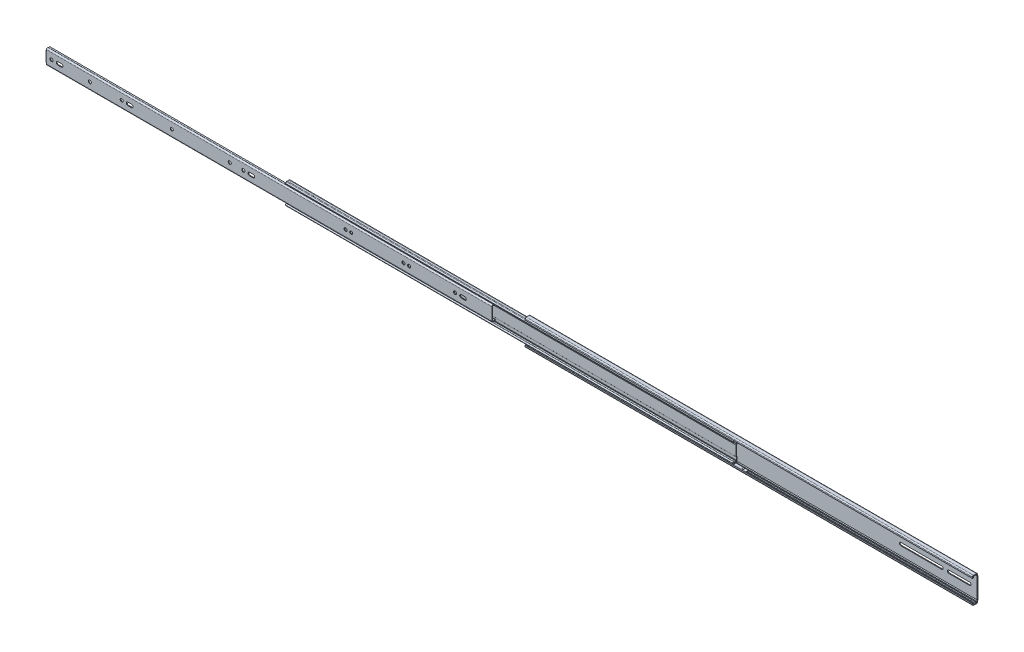
from build123d import *

# Parameters (mm, degrees)
EXTRUDE1_DEPTH      = 711.2
EXTRUDE_THIN3_DEPTH = 711.2
EXTRUDE_THIN4_DEPTH = 709.93
SKETCH4_W           = 1.7018
SKETCH4_H           = 3.807139541
CUT_EXTRUDE1_DEPTH  = 10.525
SKETCH5_W           = 1.1938
SKETCH5_H           = 8.001
EXTRUDE2_DEPTH      = 6.9088
FILLET1_R           = 0.508
FILLET2_R           = 1.7018
SKETCH6_R           = 2.4384
CUT_EXTRUDE2_DEPTH  = 1.1938
SKETCH7_R           = 2.4384
CUT_A_DEPTH         = 1.1938
SKETCH8_R           = 2.4384
CUT_B_DEPTH         = 1.1938
SKETCH9_R           = 2.4384
CUT_C_DEPTH         = 1.1938
SKETCH10_R          = 2.4384
CUT_D_DEPTH         = 1.1938
SKETCH11_R          = 2.4384
CUT_E_DEPTH         = 1.1938
SKETCH12_R          = 2.4384
CUT_F_DEPTH         = 1.1938
SKETCH13_R          = 2.286
CUT_EXTRUDE9_DEPTH  = 1.1938
LPATTERN1_COUNT     = 14
LPATTERN1_PITCH     = 25.4
SKETCH15_W          = 4.064
SKETCH15_H          = 0.762
EXTRUDE3_DEPTH      = 336.55
EXTRUDE3_DEPTH_BACK = 6.35
LPATTERN2_COUNT     = 12
LPATTERN2_PITCH     = 25.4
SKETCH17_W          = 3.81
SKETCH17_H          = 0.762
EXTRUDE4_DEPTH      = 285.75
EXTRUDE4_DEPTH_BACK = 6.35


with BuildPart() as part:
    # Sketch1 → Extrude1 (new body)
    with BuildSketch(Plane(origin=(0, 0, 0), x_dir=(0, 0, -1), z_dir=(1, 0, 0))):
        with BuildLine():
            Line((4.7498, 0), (3.556, 0))
            Line((3.556, 0), (3.556, 16.3322))
            Line((3.556, 16.3322), (2.794, 17.7546))
            Line((2.794, 17.7546), (2.794, 19.1897))
            ThreePointArc((2.794, 19.1897), (2.719605122, 19.369305122), (2.54, 19.4437))
            Line((2.54, 19.4437), (0.704935806, 19.4437))
            ThreePointArc((0.704935806, 19.4437), (0, 19.6088), (-0.704935806, 19.4437))
            Line((-0.704935806, 19.4437), (-2.286, 19.4437))
            ThreePointArc((-2.286, 19.4437), (-2.645210245, 19.294910245), (-2.794, 18.9357))
            Line((-2.794, 18.9357), (-2.794, 17.0942))
            Line((-2.794, 17.0942), (-3.9878, 17.0942))
            Line((-3.9878, 17.0942), (-3.9878, 18.9357))
            ThreePointArc((-3.9878, 18.9357), (-3.48935432, 20.13905432), (-2.286, 20.6375))
            Line((-2.286, 20.6375), (2.54, 20.6375))
            ThreePointArc((2.54, 20.6375), (3.563749198, 20.213449198), (3.9878, 19.1897))
            Line((3.9878, 19.1897), (3.9878, 17.7546))
            Line((3.9878, 17.7546), (4.7498, 16.3322))
            Line((4.7498, 16.3322), (4.7498, 0))
        make_face()
    extrude(amount=EXTRUDE1_DEPTH)

    # Sketch13 → Cut-Extrude9 (cut)
    with BuildSketch(Plane.XY.offset(-3.556)):
        with Locations((12.7, 0)):
            Circle(SKETCH13_R)
        with Locations((25.4, 0)):
            Circle(SKETCH13_R)
        with BuildLine():
            Line((43.942, 2.286), (57.658, 2.286))
            ThreePointArc((57.658, 2.286), (59.944, 0), (57.658, -2.286))
            Line((57.658, -2.286), (43.942, -2.286))
            ThreePointArc((43.942, -2.286), (41.656, 0), (43.942, 2.286))
        make_face()
        with BuildLine():
            Line((665.988, 2.286), (699.262, 2.286))
            ThreePointArc((699.262, 2.286), (701.548, 0), (699.262, -2.286))
            Line((699.262, -2.286), (665.988, -2.286))
            ThreePointArc((665.988, -2.286), (663.702, 0), (665.988, 2.286))
        make_face()
        with BuildLine():
            Line((589.788, 2.286), (654.812, 2.286))
            ThreePointArc((654.812, 2.286), (657.098, 0), (654.812, -2.286))
            Line((654.812, -2.286), (589.788, -2.286))
            ThreePointArc((589.788, -2.286), (587.502, 0), (589.788, 2.286))
        make_face()
    extrude(amount=-CUT_EXTRUDE9_DEPTH, mode=Mode.SUBTRACT)

    # Mirror1 3: part across plane


with BuildPart() as body_2:
    # Sketch2 → Extrude-Thin3 (new body)
    with BuildSketch(Plane(origin=(-381, 0, 0), x_dir=(0, 0, -1), z_dir=(1, 0, 0))):
        with BuildLine():
            Line((1.678205122, 13.56611667), (0.330795167, 13.56611667))
            ThreePointArc((0.330795167, 13.56611667), (-0.907153989, 14.137512866), (-2.131711722, 13.537954626))
            ThreePointArc((-2.131711722, 13.537954626), (-3.588398833, 13.622175049), (-4.000459023, 15.021902459))
            Line((-4.000459023, 15.021902459), (-2.6823632, 16.683501723))
            ThreePointArc((-2.6823632, 16.683501723), (-2.059327749, 17.098889851), (-1.31100655, 17.071763198))
            ThreePointArc((-1.31100655, 17.071763198), (0, 16.841067769), (1.31100655, 17.071763198))
            ThreePointArc((1.31100655, 17.071763198), (2.426851908, 16.924266748), (2.9464, 15.9258))
            Line((2.9464, 15.9258), (2.9464, 9.08690864))
            ThreePointArc((2.9464, 9.08690864), (2.836192787, 8.532859567), (2.522349198, 8.063159443))
            Line((2.522349198, 8.063159443), (2.062278771, 7.603089016))
            Line((2.062278771, 7.603089016), (2.062278771, 0))
            Line((2.062278771, 0), (0.868478771, 0))
            Line((0.868478771, 0), (0.868478771, 8.097577167))
            Line((0.868478771, 8.097577167), (1.678205122, 8.907303518))
            ThreePointArc((1.678205122, 8.907303518), (1.733265401, 8.989707049), (1.7526, 9.08690864))
            Line((1.7526, 9.08690864), (1.7526, 15.9258))
            ThreePointArc((1.7526, 15.9258), (1.741776081, 15.946601391), (1.718529303, 15.949674233))
            ThreePointArc((1.718529303, 15.949674233), (0, 15.647267769), (-1.718529303, 15.949674233))
            ThreePointArc((-1.718529303, 15.949674233), (-1.734119328, 15.950239372), (-1.747099233, 15.941585453))
            Line((-1.747099233, 15.941585453), (-2.845633379, 14.556766916))
            ThreePointArc((-2.845633379, 14.556766916), (-2.836333429, 14.550559856), (-2.826200697, 14.54583287))
            ThreePointArc((-2.826200697, 14.54583287), (-1.052921196, 15.326581965), (0.799909012, 14.75991667))
            Line((0.799909012, 14.75991667), (1.678205122, 14.75991667))
            Line((1.678205122, 14.75991667), (1.678205122, 13.56611667))
        make_face()
    extrude(amount=EXTRUDE_THIN3_DEPTH)

    # Mirror1: body 2 across plane


with BuildPart() as body_3:
    # Sketch3 → Extrude-Thin4 (new body)
    with BuildSketch(Plane(origin=(-762, 0, 0), x_dir=(0, 0, -1), z_dir=(1, 0, 0))):
        with BuildLine():
            Line((-4.7752, 0), (-4.7752, 9.979339541))
            ThreePointArc((-4.7752, 9.979339541), (-3.801640272, 11.595839932), (-1.917508053, 11.491255808))
            ThreePointArc((-1.917508053, 11.491255808), (-0.787981781, 11.177143004), (0.300186701, 11.613475229))
            Line((0.300186701, 11.613475229), (1.076210755, 10.706312009))
            ThreePointArc((1.076210755, 10.706312009), (-0.722289929, 9.985151804), (-2.589145852, 10.504310467))
            ThreePointArc((-2.589145852, 10.504310467), (-3.243358428, 10.540624399), (-3.5814, 9.979339541))
            Line((-3.5814, 9.979339541), (-3.5814, 0))
            Line((-3.5814, 0), (-4.7752, 0))
        make_face()
    extrude(amount=EXTRUDE_THIN4_DEPTH)

    # Sketch4 → Cut-Extrude1 (cut, through all)
    with BuildSketch(Plane.XY.offset(4.7752)):
        with Locations((-761.1491, 9.904569771)):
            Rectangle(SKETCH4_W, SKETCH4_H)
    extrude(amount=-CUT_EXTRUDE1_DEPTH, mode=Mode.SUBTRACT)

    # Sketch5 → Extrude2 (add)
    with BuildSketch(Plane.XY.offset(4.7752)):
        with Locations((-761.4031, 4.0005)):
            Rectangle(SKETCH5_W, SKETCH5_H)
    extrude(amount=-EXTRUDE2_DEPTH)

    # Fillet1
    fillet1_edges = [body_3.edges().sort_by_distance(p)[0] for p in [
        (-760.8062, 4.0005, 3.5814),
    ]]
    fillet(fillet1_edges, radius=FILLET1_R)

    # Fillet2
    fillet2_edges = [body_3.edges().sort_by_distance(p)[0] for p in [
        (-762, 4.0005, 4.7752),
    ]]
    fillet(fillet2_edges, radius=FILLET2_R)

    # Sketch6 → Cut-Extrude2 (cut)
    with BuildSketch(Plane.XY.offset(4.7752)):
        with Locations((-752.094, 0)):
            Circle(SKETCH6_R)
        with Locations((-691.388, 0)):
            Circle(SKETCH6_R)
        with Locations((-640.588, 0)):
            Circle(SKETCH6_R)
        with BuildLine():
            Line((-736.5873, -2.4384), (-742.2007, -2.4384))
            ThreePointArc((-742.2007, -2.4384), (-744.6391, 0), (-742.2007, 2.4384))
            Line((-742.2007, 2.4384), (-736.5873, 2.4384))
            ThreePointArc((-736.5873, 2.4384), (-734.1489, 0), (-736.5873, -2.4384))
        make_face()
        with BuildLine():
            Line((-625.0813, -2.4384), (-630.6947, -2.4384))
            ThreePointArc((-630.6947, -2.4384), (-633.1331, 0), (-630.6947, 2.4384))
            Line((-630.6947, 2.4384), (-625.0813, 2.4384))
            ThreePointArc((-625.0813, 2.4384), (-622.6429, 0), (-625.0813, -2.4384))
        make_face()
    extrude(amount=-CUT_EXTRUDE2_DEPTH, mode=Mode.SUBTRACT)

    # Sketch7 → Cut A (cut)
    with BuildSketch(Plane.XY.offset(4.7752)):
        with Locations((-560.959, 0)):
            Circle(SKETCH7_R)
    extrude(amount=-CUT_A_DEPTH, mode=Mode.SUBTRACT)

    # Sketch8 → Cut B (cut)
    with BuildSketch(Plane(origin=(33.28572008, 2.833820848, 4.7752), x_dir=(1, 0, 0), z_dir=(0, 0, 1))):
        with Locations((-502.16972008, -2.833820848)):
            Circle(SKETCH8_R)
    extrude(amount=-CUT_B_DEPTH, mode=Mode.SUBTRACT)

    # Sketch9 → Cut C (cut)
    with BuildSketch(Plane.XY.offset(4.7752)):
        with Locations((-447.294, 0)):
            Circle(SKETCH9_R)
        with BuildLine():
            Line((-431.7873, -2.4384), (-437.4007, -2.4384))
            ThreePointArc((-437.4007, -2.4384), (-439.8391, 0), (-437.4007, 2.4384))
            Line((-437.4007, 2.4384), (-431.7873, 2.4384))
            ThreePointArc((-431.7873, 2.4384), (-429.3489, 0), (-431.7873, -2.4384))
        make_face()
    extrude(amount=-CUT_C_DEPTH, mode=Mode.SUBTRACT)

    # Sketch10 → Cut D (cut)
    with BuildSketch(Plane.XY.offset(4.7752)):
        with Locations((-284.734, 0)):
            Circle(SKETCH10_R)
        with Locations((-275.844, 0)):
            Circle(SKETCH10_R)
    extrude(amount=-CUT_D_DEPTH, mode=Mode.SUBTRACT)

    # Sketch11 → Cut E (cut)
    with BuildSketch(Plane(origin=(55.847663356, 2.141084094, 4.7752), x_dir=(1, 0, 0), z_dir=(0, 0, 1))):
        with Locations((-248.506663356, -2.141084094)):
            Circle(SKETCH11_R)
        with Locations((-239.616663356, -2.141084094)):
            Circle(SKETCH11_R)
    extrude(amount=-CUT_E_DEPTH, mode=Mode.SUBTRACT)

    # Sketch12 → Cut F (cut)
    with BuildSketch(Plane(origin=(338.891405188, 2.462451908, 4.7752), x_dir=(1, 0, 0), z_dir=(0, 0, 1))):
        with Locations((-449.635405188, -2.462451908)):
            Circle(SKETCH12_R)
        with BuildLine():
            Line((-439.742105188, -4.900851908), (-434.128705188, -4.900851908))
            ThreePointArc((-434.128705188, -4.900851908), (-431.690305188, -2.462451908), (-434.128705188, -0.024051908))
            Line((-434.128705188, -0.024051908), (-439.742105188, -0.024051908))
            ThreePointArc((-439.742105188, -0.024051908), (-442.180505188, -2.462451908), (-439.742105188, -4.900851908))
        make_face()
    extrude(amount=-CUT_F_DEPTH, mode=Mode.SUBTRACT)

    # Mirror1 2: body 3 across plane


with BuildPart() as body_2_1:
    add(body_2.part)
    add(body_2.part.mirror(Plane.ZX))


with BuildPart() as body_3_1:
    add(body_3.part)
    add(body_3.part.mirror(Plane.ZX))


with BuildPart() as part_1:
    add(part.part)
    add(part.part.mirror(Plane.ZX))


with BuildPart() as body_4:
    # Sketch14 → Revolve1 (revolve)
    with BuildSketch(Plane(origin=(12.7, 0, 0), x_dir=(0, 0, -1), z_dir=(1, 0, 0))):
        with BuildLine():
            Line((0, 19.6088), (0, 16.841067769))
            ThreePointArc((0, 16.841067769), (1.383866115, 18.224933885), (0, 19.6088))
        make_face()
    revolve(axis=Axis((12.7, 20.062006868, 0), (0, -1, 0)))


with BuildPart() as lpattern1_1:
    # LPattern1: pattern copy
    add(body_4.part.moved(Location(Vector(1, 0, 0) * (1 * LPATTERN1_PITCH))))


with BuildPart() as lpattern1_2:
    # LPattern1: pattern copy
    add(body_4.part.moved(Location(Vector(1, 0, 0) * (2 * LPATTERN1_PITCH))))


with BuildPart() as lpattern1_3:
    # LPattern1: pattern copy
    add(body_4.part.moved(Location(Vector(1, 0, 0) * (3 * LPATTERN1_PITCH))))


with BuildPart() as lpattern1_4:
    # LPattern1: pattern copy
    add(body_4.part.moved(Location(Vector(1, 0, 0) * (4 * LPATTERN1_PITCH))))


with BuildPart() as lpattern1_5:
    # LPattern1: pattern copy
    add(body_4.part.moved(Location(Vector(1, 0, 0) * (5 * LPATTERN1_PITCH))))


with BuildPart() as lpattern1_6:
    # LPattern1: pattern copy
    add(body_4.part.moved(Location(Vector(1, 0, 0) * (6 * LPATTERN1_PITCH))))


with BuildPart() as lpattern1_7:
    # LPattern1: pattern copy
    add(body_4.part.moved(Location(Vector(1, 0, 0) * (7 * LPATTERN1_PITCH))))


with BuildPart() as lpattern1_8:
    # LPattern1: pattern copy
    add(body_4.part.moved(Location(Vector(1, 0, 0) * (8 * LPATTERN1_PITCH))))


with BuildPart() as lpattern1_9:
    # LPattern1: pattern copy
    add(body_4.part.moved(Location(Vector(1, 0, 0) * (9 * LPATTERN1_PITCH))))


with BuildPart() as lpattern1_10:
    # LPattern1: pattern copy
    add(body_4.part.moved(Location(Vector(1, 0, 0) * (10 * LPATTERN1_PITCH))))


with BuildPart() as lpattern1_11:
    # LPattern1: pattern copy
    add(body_4.part.moved(Location(Vector(1, 0, 0) * (11 * LPATTERN1_PITCH))))


with BuildPart() as lpattern1_12:
    # LPattern1: pattern copy
    add(body_4.part.moved(Location(Vector(1, 0, 0) * (12 * LPATTERN1_PITCH))))


with BuildPart() as lpattern1_13:
    # LPattern1: pattern copy
    add(body_4.part.moved(Location(Vector(1, 0, 0) * (13 * LPATTERN1_PITCH))))


with BuildPart() as body_4_1:
    add(body_4.part)

    add(lpattern1_1.part)  # Extrude3 merges LPattern1_1

    add(lpattern1_2.part)  # Extrude3 merges LPattern1_2

    add(lpattern1_3.part)  # Extrude3 merges LPattern1_3

    add(lpattern1_4.part)  # Extrude3 merges LPattern1_4

    add(lpattern1_5.part)  # Extrude3 merges LPattern1_5

    add(lpattern1_6.part)  # Extrude3 merges LPattern1_6

    add(lpattern1_7.part)  # Extrude3 merges LPattern1_7

    add(lpattern1_8.part)  # Extrude3 merges LPattern1_8

    add(lpattern1_9.part)  # Extrude3 merges LPattern1_9

    add(lpattern1_10.part)  # Extrude3 merges LPattern1_10

    add(lpattern1_11.part)  # Extrude3 merges LPattern1_11

    add(lpattern1_12.part)  # Extrude3 merges LPattern1_12

    add(lpattern1_13.part)  # Extrude3 merges LPattern1_13
    # Sketch15 → Extrude3 (add, two sides)
    with BuildSketch(Plane(origin=(12.7, 0, 0), x_dir=(0, 0, -1), z_dir=(1, 0, 0))) as extrude3_sk:
        with Locations((0, 18.224933885)):
            Rectangle(SKETCH15_W, SKETCH15_H)
    extrude(amount=EXTRUDE3_DEPTH)
    extrude(extrude3_sk.sketch, amount=-EXTRUDE3_DEPTH_BACK)


with BuildPart() as body_5:
    # Sketch16 → Revolve2 (revolve)
    with BuildSketch(Plane(origin=(-368.3, 0, 0), x_dir=(0, 0, -1), z_dir=(1, 0, 0))):
        with BuildLine():
            Line((-0.889, 14.13761667), (-0.889, 11.174372289))
            ThreePointArc((-0.889, 11.174372289), (0.592622191, 12.655994479), (-0.889, 14.13761667))
        make_face()
    revolve(axis=Axis((-368.3, 14.576458581, 0.889), (0, -1, 0)))


with BuildPart() as lpattern2_1:
    # LPattern2: pattern copy
    add(body_5.part.moved(Location(Vector(1, 0, 0) * (1 * LPATTERN2_PITCH))))


with BuildPart() as lpattern2_2:
    # LPattern2: pattern copy
    add(body_5.part.moved(Location(Vector(1, 0, 0) * (2 * LPATTERN2_PITCH))))


with BuildPart() as lpattern2_3:
    # LPattern2: pattern copy
    add(body_5.part.moved(Location(Vector(1, 0, 0) * (3 * LPATTERN2_PITCH))))


with BuildPart() as lpattern2_4:
    # LPattern2: pattern copy
    add(body_5.part.moved(Location(Vector(1, 0, 0) * (4 * LPATTERN2_PITCH))))


with BuildPart() as lpattern2_5:
    # LPattern2: pattern copy
    add(body_5.part.moved(Location(Vector(1, 0, 0) * (5 * LPATTERN2_PITCH))))


with BuildPart() as lpattern2_6:
    # LPattern2: pattern copy
    add(body_5.part.moved(Location(Vector(1, 0, 0) * (6 * LPATTERN2_PITCH))))


with BuildPart() as lpattern2_7:
    # LPattern2: pattern copy
    add(body_5.part.moved(Location(Vector(1, 0, 0) * (7 * LPATTERN2_PITCH))))


with BuildPart() as lpattern2_8:
    # LPattern2: pattern copy
    add(body_5.part.moved(Location(Vector(1, 0, 0) * (8 * LPATTERN2_PITCH))))


with BuildPart() as lpattern2_9:
    # LPattern2: pattern copy
    add(body_5.part.moved(Location(Vector(1, 0, 0) * (9 * LPATTERN2_PITCH))))


with BuildPart() as lpattern2_10:
    # LPattern2: pattern copy
    add(body_5.part.moved(Location(Vector(1, 0, 0) * (10 * LPATTERN2_PITCH))))


with BuildPart() as lpattern2_11:
    # LPattern2: pattern copy
    add(body_5.part.moved(Location(Vector(1, 0, 0) * (11 * LPATTERN2_PITCH))))


with BuildPart() as body_5_1:
    add(body_5.part)

    add(lpattern2_1.part)  # Extrude4 merges LPattern2_1

    add(lpattern2_2.part)  # Extrude4 merges LPattern2_2

    add(lpattern2_3.part)  # Extrude4 merges LPattern2_3

    add(lpattern2_4.part)  # Extrude4 merges LPattern2_4

    add(lpattern2_5.part)  # Extrude4 merges LPattern2_5

    add(lpattern2_6.part)  # Extrude4 merges LPattern2_6

    add(lpattern2_7.part)  # Extrude4 merges LPattern2_7

    add(lpattern2_8.part)  # Extrude4 merges LPattern2_8

    add(lpattern2_9.part)  # Extrude4 merges LPattern2_9

    add(lpattern2_10.part)  # Extrude4 merges LPattern2_10

    add(lpattern2_11.part)  # Extrude4 merges LPattern2_11
    # Sketch17 → Extrude4 (add, two sides)
    with BuildSketch(Plane(origin=(-368.3, 0, 0), x_dir=(0, 0, -1), z_dir=(1, 0, 0))) as extrude4_sk:
        with Locations((-0.9144, 12.655994479)):
            Rectangle(SKETCH17_W, SKETCH17_H)
    extrude(amount=EXTRUDE4_DEPTH)
    extrude(extrude4_sk.sketch, amount=-EXTRUDE4_DEPTH_BACK)


with BuildPart() as body_6:
    # Mirror2: mirrored copy
    add(body_4_1.part.mirror(Plane.ZX))


with BuildPart() as body_7:
    # Mirror2 2: mirrored copy
    add(body_5_1.part.mirror(Plane.ZX))


solid = Compound([body_2_1.part, body_3_1.part, part_1.part, body_4_1.part, body_5_1.part, body_6.part, body_7.part])
